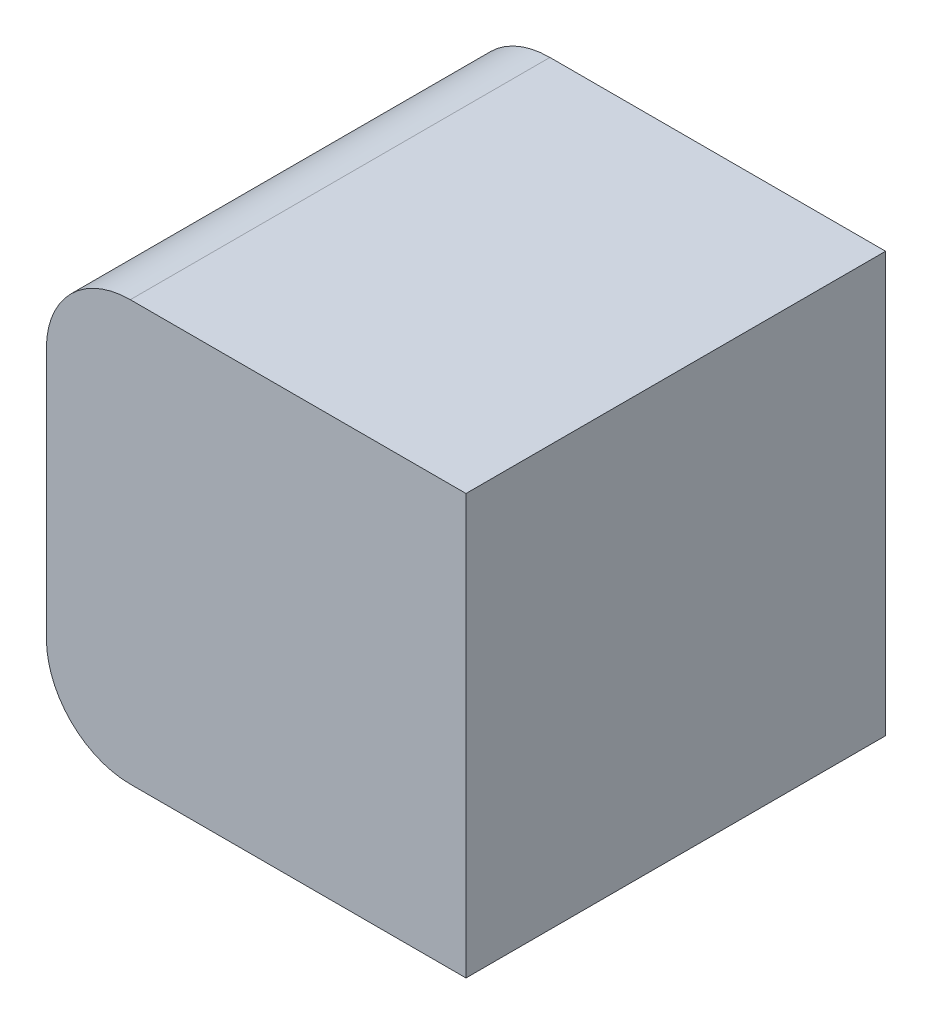
from build123d import *

# Parameters (mm, degrees)
SKETCH5_W           = 1000
SKETCH5_H           = 1000
BOSS_EXTRUDE2_DEPTH = 1000
SKETCH7_R           = 250
CUT_EXTRUDE2_DEPTH  = 400
FILLET1_R           = 200


with BuildPart() as part:
    # Sketch5 → Boss-Extrude2 (new body)
    with BuildSketch(Plane(origin=(0, 0, 0), x_dir=(0, 0, -1), z_dir=(1, 0, 0))):
        with Locations((500, 500)):
            Rectangle(SKETCH5_W, SKETCH5_H)
    extrude(amount=BOSS_EXTRUDE2_DEPTH)

    # Sketch6 → Cut-Revolve5 (revolve, cut)
    with BuildSketch(Plane(origin=(500, 0, 0), x_dir=(0, 0, -1), z_dir=(1, 0, 0))):
        with BuildLine():
            Line((83.20002133, 500), (916.79997867, 500))
            ThreePointArc((916.79997867, 500), (500, 916.79997867), (83.20002133, 500))
        make_face()
    revolve(axis=Axis((500, 500, -83.20002133), (0, 0, -1)), mode=Mode.SUBTRACT)

    # Sketch7 → Cut-Extrude2 (cut)
    with BuildSketch(Plane(origin=(0, 0, 0), x_dir=(0, 0, -1), z_dir=(1, 0, 0))):
        with Locations((500, 500)):
            Circle(SKETCH7_R)
    extrude(amount=CUT_EXTRUDE2_DEPTH, mode=Mode.SUBTRACT)

    # Fillet1
    fillet1_edges = [part.edges().sort_by_distance(p)[0] for p in [
        (0, 1000, -500),
        (0, 0, -500),
    ]]
    fillet(fillet1_edges, radius=FILLET1_R)


solid = part.part
